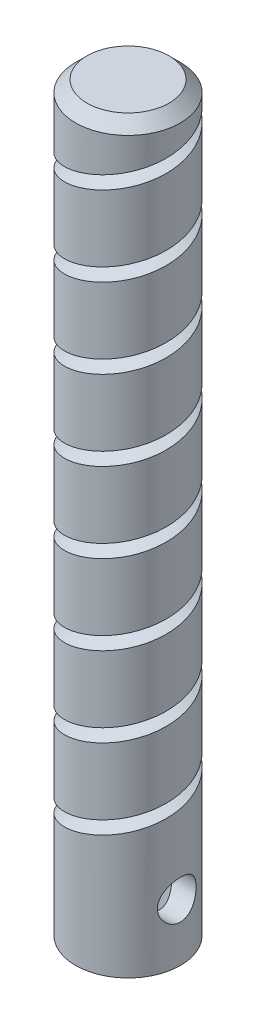
from build123d import *

# Parameters (mm, degrees)
SKETCH1_R               = 4.6
BOSS_EXTRUDE1_DEPTH     = 65
CHAMFER1_SIZE           = 1
CUT_SWEEP2_PITCH        = 7
CUT_SWEEP2_HEIGHT       = 56
CUT_SWEEP2_RADIUS       = 4.6
CUT_SWEEP2_START_ANGLE  = -90
CUT_EXTRUDE1_DEPTH      = 65
SKETCH5_R               = 2.75
CUT_EXTRUDE2_DEPTH      = 12
SKETCH6_R               = 1.7
CUT_EXTRUDE4_DEPTH      = 12
CUT_EXTRUDE4_DEPTH_BACK = 12


with BuildPart() as part:
    # Sketch1 → Boss-Extrude1 (new body)
    with BuildSketch(Plane(origin=(0, 0, 0), x_dir=(1, 0, 0), z_dir=(0, 1, 0))):
        with Locations(Location((0, 0, 0), (0, 0, 270))):
            Circle(SKETCH1_R)
    extrude(amount=BOSS_EXTRUDE1_DEPTH)

    # Chamfer1
    chamfer1_edges = [part.edges().sort_by_distance(p)[0] for p in [
        (0, 65, -4.6),
    ]]
    chamfer(chamfer1_edges, length=CHAMFER1_SIZE)

    # Cut-Sweep2: sweep along a helix
    with BuildLine() as cut_sweep2_path:
        add(Helix(CUT_SWEEP2_PITCH, CUT_SWEEP2_HEIGHT, CUT_SWEEP2_RADIUS, center=(0, 65, 0), direction=(0, -1, 0), mode=Mode.PRIVATE).rotate(Axis((0, 65, 0), (0, -1, 0)), CUT_SWEEP2_START_ANGLE))
    # Sketch3 → Cut-Sweep2 (sweep, cut)
    with BuildSketch(Plane.XY):
        Polygon((-3.6, 65), (-5.1, 65.866025404), (-5.1, 64.133974596), align=None)
    sweep(path=cut_sweep2_path.line, is_frenet=True, mode=Mode.SUBTRACT)

    # Sketch4 → Cut-Extrude1 (cut)
    with BuildSketch(Plane.XY):
        Polygon((-3.6, 9), (-4.6, 9.577350269), (-4.6, 8.422649731), align=None)
    extrude(amount=-CUT_EXTRUDE1_DEPTH, mode=Mode.SUBTRACT)

    # Sketch5 → Cut-Extrude2 (cut)
    with BuildSketch(Plane.XZ):
        with Locations(Location((0, 0, 0), (0, 0, 270))):
            Circle(SKETCH5_R)
    extrude(amount=-CUT_EXTRUDE2_DEPTH, mode=Mode.SUBTRACT)

    # Sketch6 → Cut-Extrude4 (cut, two sides)
    with BuildSketch(Plane(origin=(0, 0, 0), x_dir=(0, 0, -1), z_dir=(1, 0, 0))) as cut_extrude4_sk:
        with Locations(Location((0, 5, 0), (0, 0, 180))):
            Circle(SKETCH6_R)
    extrude(amount=CUT_EXTRUDE4_DEPTH, mode=Mode.SUBTRACT)
    extrude(cut_extrude4_sk.sketch, amount=-CUT_EXTRUDE4_DEPTH_BACK, mode=Mode.SUBTRACT)


solid = part.part
